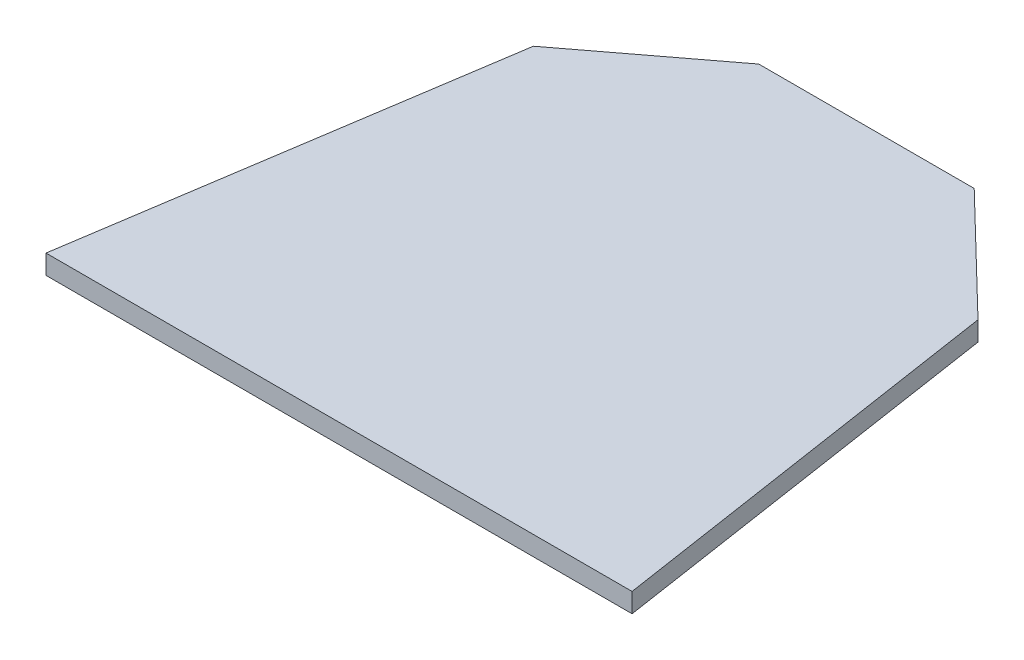
from build123d import *

# Parameters (mm, degrees)
BOSS_EXTRU_1_DEPTH = 2


with BuildPart() as part:
    # Esquisse1 → Boss.-Extru.1 (new body)
    with BuildSketch(Plane(origin=(0, 0, 0), x_dir=(1, 0, 0), z_dir=(0, 1, 0))):
        Polygon((60.51013277, 0), (54.074558367, 42.149300971), (42.138299908, 53.693855418), (19.898246387, 53.693855418), (6.665538932, 43.655436017), (0, 0), align=None)
    extrude(amount=BOSS_EXTRU_1_DEPTH)


solid = part.part
